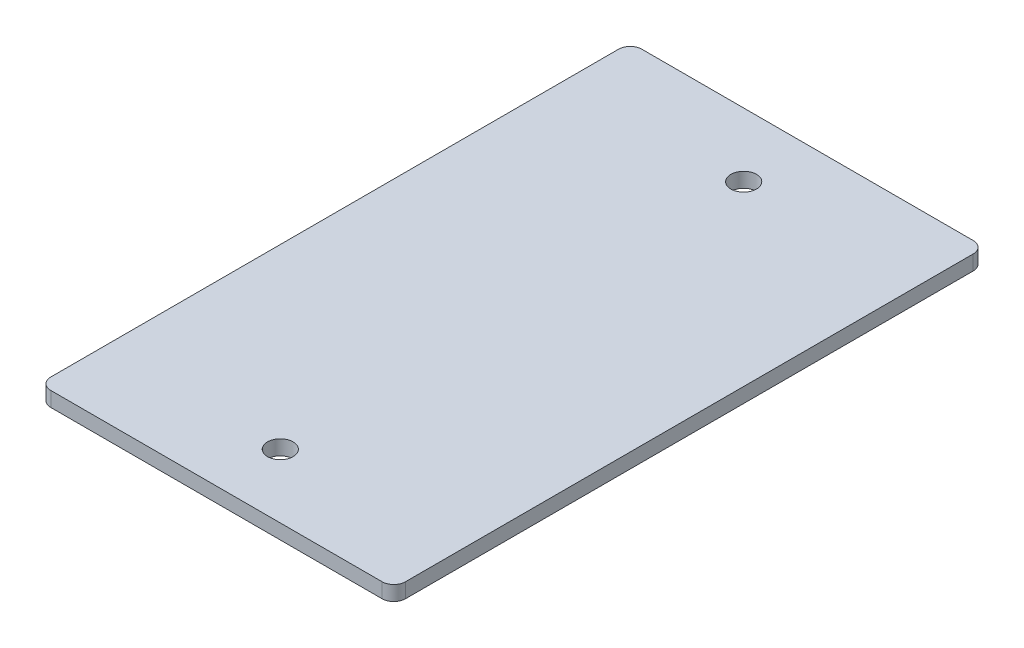
from build123d import *

# Parameters (mm, degrees)
SKETCH1_W           = 76.2
SKETCH1_H           = 127
SKETCH1_R           = 2.75
BOSS_EXTRUDE1_DEPTH = 3.175
FILLET1_R           = 2.5


with BuildPart() as part:
    # Sketch1 → Boss-Extrude1 (new body)
    with BuildSketch(Plane(origin=(0, 0, 0), x_dir=(1, 0, 0), z_dir=(0, 1, 0))):
        Rectangle(SKETCH1_W, SKETCH1_H)
        with Locations((0, 49.785)):
            Circle(SKETCH1_R, mode=Mode.SUBTRACT)
        with Locations((0, -49.785)):
            Circle(SKETCH1_R, mode=Mode.SUBTRACT)
    extrude(amount=BOSS_EXTRUDE1_DEPTH)

    # Fillet1
    fillet1_edges = [part.edges().sort_by_distance(p)[0] for p in [
        (38.1, 1.5875, 63.5),
        (-38.1, 1.5875, 63.5),
        (-38.1, 1.5875, -63.5),
        (38.1, 1.5875, -63.5),
    ]]
    fillet(fillet1_edges, radius=FILLET1_R)


solid = part.part
